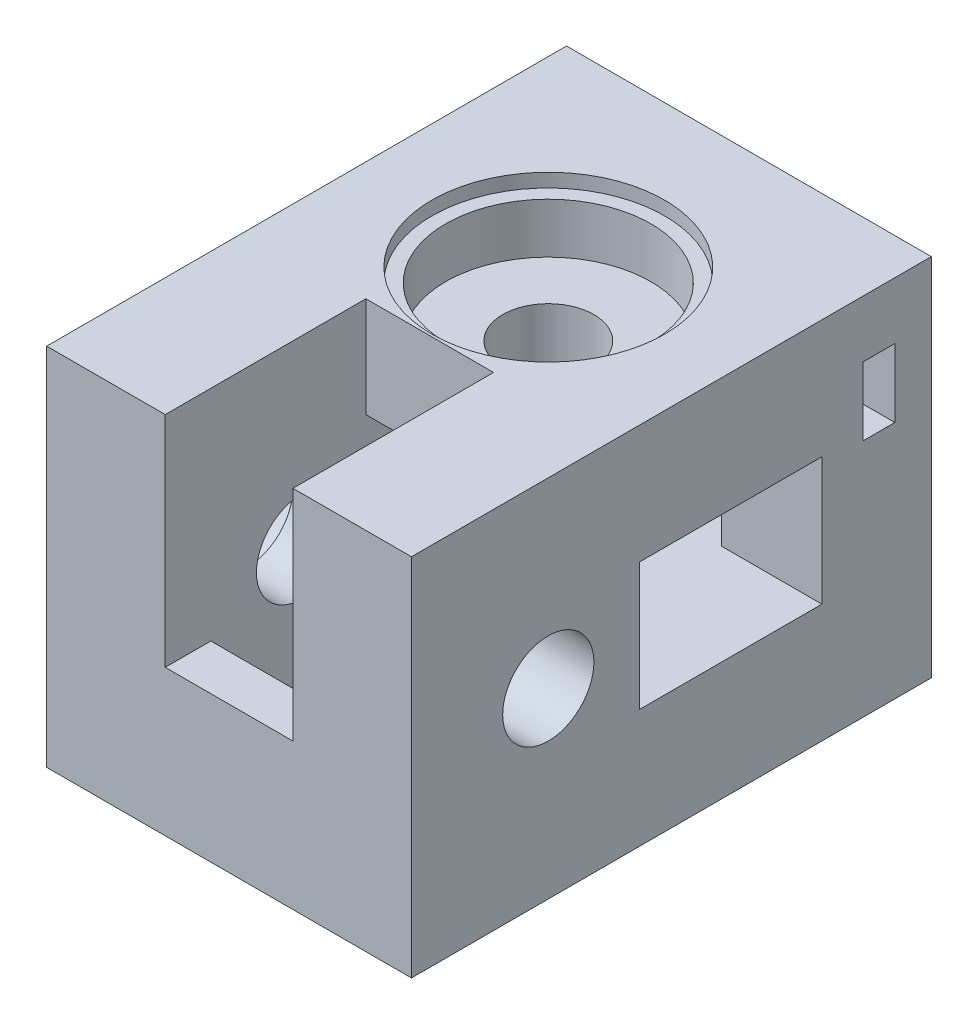
from build123d import *

# Parameters (mm, degrees)
ESQUISSE1_W              = 40
ESQUISSE1_H              = 40
BOSS_EXTRU_1_DEPTH       = 50
ESQUISSE2_R              = 5
ENL_V_MAT_EXTRU_1_DEPTH  = 41
ESQUISSE3_R              = 5
ENL_V_MAT_EXTRU_2_DEPTH  = 41
ESQUISSE4_W              = 22
ESQUISSE4_H              = 14
ENL_V_MAT_EXTRU_3_DEPTH  = 29
ESQUISSE5_W              = 14
ESQUISSE5_H              = 20
ENL_V_MAT_EXTRU_4_DEPTH  = 29
ESQUISSE6_W              = 20
ESQUISSE6_H              = 14
ENL_V_MAT_EXTRU_5_DEPTH  = 24
ESQUISSE7_W              = 14
ESQUISSE7_H              = 22
ENL_V_MAT_EXTRU_6_DEPTH  = 24
ESQUISSE10_R             = 11.25
ENL_V_MAT_EXTRU_9_DEPTH  = 7
ESQUISSE11_R             = 12.75
ENL_V_MAT_EXTRU_10_DEPTH = 1.5
ESQUISSE14_R             = 11.25
ENL_V_MAT_EXTRU_11_DEPTH = 7
ESQUISSE15_R             = 12.75
ENL_V_MAT_EXTRU_12_DEPTH = 1.5
ESQUISSE16_W             = 40
ESQUISSE16_H             = 40
BOSS_EXTRU_2_DEPTH       = 7
ESQUISSE17_R             = 2.25
ENL_V_MAT_EXTRU_13_DEPTH = 15
ESQUISSE18_W             = 3.5
ESQUISSE18_H             = 7.5
ENL_V_MAT_EXTRU_14_DEPTH = 12
ESQUISSE19_W             = 7.5
ESQUISSE19_H             = 3.5
ENL_V_MAT_EXTRU_15_DEPTH = 12


with BuildPart() as part:
    # Esquisse1 → Boss.-Extru.1 (new body)
    with BuildSketch(Plane.XY):
        with Locations((-20, 20)):
            Rectangle(ESQUISSE1_W, ESQUISSE1_H)
    extrude(amount=BOSS_EXTRU_1_DEPTH)

    # Esquisse2 → Enlèv. mat.-Extru.1 (cut, through all)
    with BuildSketch(Plane(origin=(0, 40, 0), x_dir=(1, 0, 0), z_dir=(0, 1, 0))):
        with Locations(Location((-20, -15, 0), (0, 0, 270))):  # turned: the seam where the file's is
            Circle(ESQUISSE2_R)
    extrude(amount=-ENL_V_MAT_EXTRU_1_DEPTH, mode=Mode.SUBTRACT)

    # Esquisse3 → Enlèv. mat.-Extru.2 (cut, through all)
    with BuildSketch(Plane.ZY.offset(40)):
        with Locations((35, 20)):
            Circle(ESQUISSE3_R)
    extrude(amount=-ENL_V_MAT_EXTRU_2_DEPTH, mode=Mode.SUBTRACT)

    # Esquisse4 → Enlèv. mat.-Extru.3 (cut)
    with BuildSketch(Plane.ZY.offset(40)):
        with Locations((11, 20)):
            Rectangle(ESQUISSE4_W, ESQUISSE4_H)
    extrude(amount=-ENL_V_MAT_EXTRU_3_DEPTH, mode=Mode.SUBTRACT)

    # Esquisse5 → Enlèv. mat.-Extru.4 (cut)
    with BuildSketch(Plane.XZ):
        with Locations((-20, 35)):
            Rectangle(ESQUISSE5_W, ESQUISSE5_H)
    extrude(amount=-ENL_V_MAT_EXTRU_4_DEPTH, mode=Mode.SUBTRACT)

    # Esquisse6 → Enlèv. mat.-Extru.5 (cut)
    with BuildSketch(Plane(origin=(0, 0, 0), x_dir=(0, 0, -1), z_dir=(1, 0, 0))):
        with Locations((-15, 20)):
            Rectangle(ESQUISSE6_W, ESQUISSE6_H)
    extrude(amount=-ENL_V_MAT_EXTRU_5_DEPTH, mode=Mode.SUBTRACT)

    # Esquisse7 → Enlèv. mat.-Extru.6 (cut)
    with BuildSketch(Plane(origin=(0, 40, 0), x_dir=(1, 0, 0), z_dir=(0, 1, 0))):
        with Locations((-20, -39)):
            Rectangle(ESQUISSE7_W, ESQUISSE7_H)
    extrude(amount=-ENL_V_MAT_EXTRU_6_DEPTH, mode=Mode.SUBTRACT)

    # Esquisse10 → Enlèv. mat.-Extru.9 (cut)
    with BuildSketch(Plane(origin=(0, 40, 0), x_dir=(1, 0, 0), z_dir=(0, 1, 0))):
        with Locations(Location((-20, -15, 0), (0, 0, 270))):  # turned: the seam where the file's is
            Circle(ESQUISSE10_R)
    extrude(amount=-ENL_V_MAT_EXTRU_9_DEPTH, mode=Mode.SUBTRACT)

    # Esquisse11 → Enlèv. mat.-Extru.10 (cut)
    with BuildSketch(Plane(origin=(0, 40, 0), x_dir=(1, 0, 0), z_dir=(0, 1, 0))):
        with Locations(Location((-20, -15, 0), (0, 0, 270))):  # turned: the seam where the file's is
            Circle(ESQUISSE11_R)
    extrude(amount=-ENL_V_MAT_EXTRU_10_DEPTH, mode=Mode.SUBTRACT)

    # Esquisse14 → Enlèv. mat.-Extru.11 (cut)
    with BuildSketch(Plane.ZY.offset(40)):
        with Locations((35, 20)):
            Circle(ESQUISSE14_R)
    extrude(amount=-ENL_V_MAT_EXTRU_11_DEPTH, mode=Mode.SUBTRACT)

    # Esquisse15 → Enlèv. mat.-Extru.12 (cut)
    with BuildSketch(Plane.ZY.offset(40)):
        with Locations((35, 20)):
            Circle(ESQUISSE15_R)
    extrude(amount=-ENL_V_MAT_EXTRU_12_DEPTH, mode=Mode.SUBTRACT)

    # Esquisse16 → Boss.-Extru.2 (add)
    with BuildSketch(Plane(origin=(0, 0, 0), x_dir=(-1, 0, 0), z_dir=(0, 0, -1))):
        with Locations((20, 20)):
            Rectangle(ESQUISSE16_W, ESQUISSE16_H)
    extrude(amount=BOSS_EXTRU_2_DEPTH)

    # Esquisse17 → Enlèv. mat.-Extru.13 (cut)
    with BuildSketch(Plane(origin=(0, 0, -7), x_dir=(-1, 0, 0), z_dir=(0, 0, -1))):
        with Locations((7.5, 30)):
            Circle(ESQUISSE17_R)
        with Locations((30, 7.5)):
            Circle(ESQUISSE17_R)
    extrude(amount=-ENL_V_MAT_EXTRU_13_DEPTH, mode=Mode.SUBTRACT)

    # Esquisse18 → Enlèv. mat.-Extru.14 (cut)
    with BuildSketch(Plane(origin=(0, 0, 0), x_dir=(0, 0, -1), z_dir=(1, 0, 0))):
        with Locations((1.25, 30)):
            Rectangle(ESQUISSE18_W, ESQUISSE18_H)
    extrude(amount=-ENL_V_MAT_EXTRU_14_DEPTH, mode=Mode.SUBTRACT)

    # Esquisse19 → Enlèv. mat.-Extru.15 (cut)
    with BuildSketch(Plane.XZ):
        with Locations((-30, -1.25)):
            Rectangle(ESQUISSE19_W, ESQUISSE19_H)
    extrude(amount=-ENL_V_MAT_EXTRU_15_DEPTH, mode=Mode.SUBTRACT)


solid = part.part
